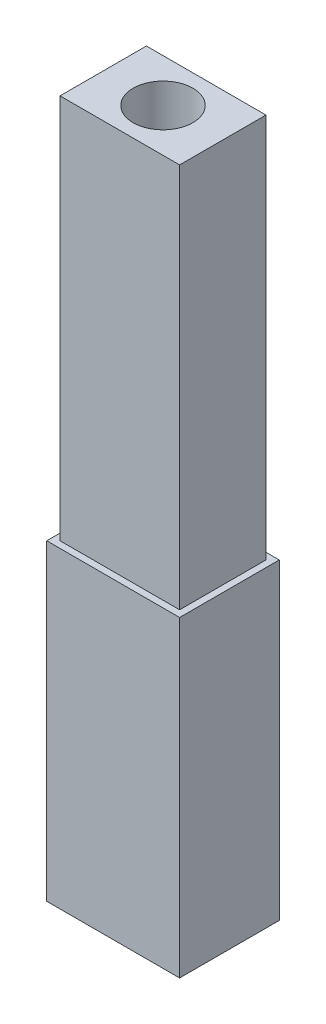
from build123d import *

# Parameters (mm, degrees)
SKETCH1_W           = 20
SKETCH1_H           = 15
BOSS_EXTRUDE1_DEPTH = 47
SKETCH2_W           = 18
SKETCH2_H           = 13
BOSS_EXTRUDE2_DEPTH = 58
SKETCH3_R           = 4.5
CUT_EXTRUDE1_DEPTH  = 58


with BuildPart() as part:
    # Sketch1 → Boss-Extrude1 (new body)
    with BuildSketch(Plane(origin=(0, 0, 0), x_dir=(1, 0, 0), z_dir=(0, 1, 0))):
        with Locations((10, 7.5)):
            Rectangle(SKETCH1_W, SKETCH1_H)
    extrude(amount=BOSS_EXTRUDE1_DEPTH)

    # Sketch2 → Boss-Extrude2 (add)
    with BuildSketch(Plane(origin=(0, 47, 0), x_dir=(1, 0, 0), z_dir=(0, 1, 0))):
        with Locations((10, 7.5)):
            Rectangle(SKETCH2_W, SKETCH2_H)
    extrude(amount=BOSS_EXTRUDE2_DEPTH)

    # Sketch3 → Cut-Extrude1 (cut)
    with BuildSketch(Plane(origin=(0, 105, 0), x_dir=(1, 0, 0), z_dir=(0, 1, 0))):
        with Locations((10, 7.5)):
            Circle(SKETCH3_R)
    extrude(amount=-CUT_EXTRUDE1_DEPTH, mode=Mode.SUBTRACT)


solid = part.part
